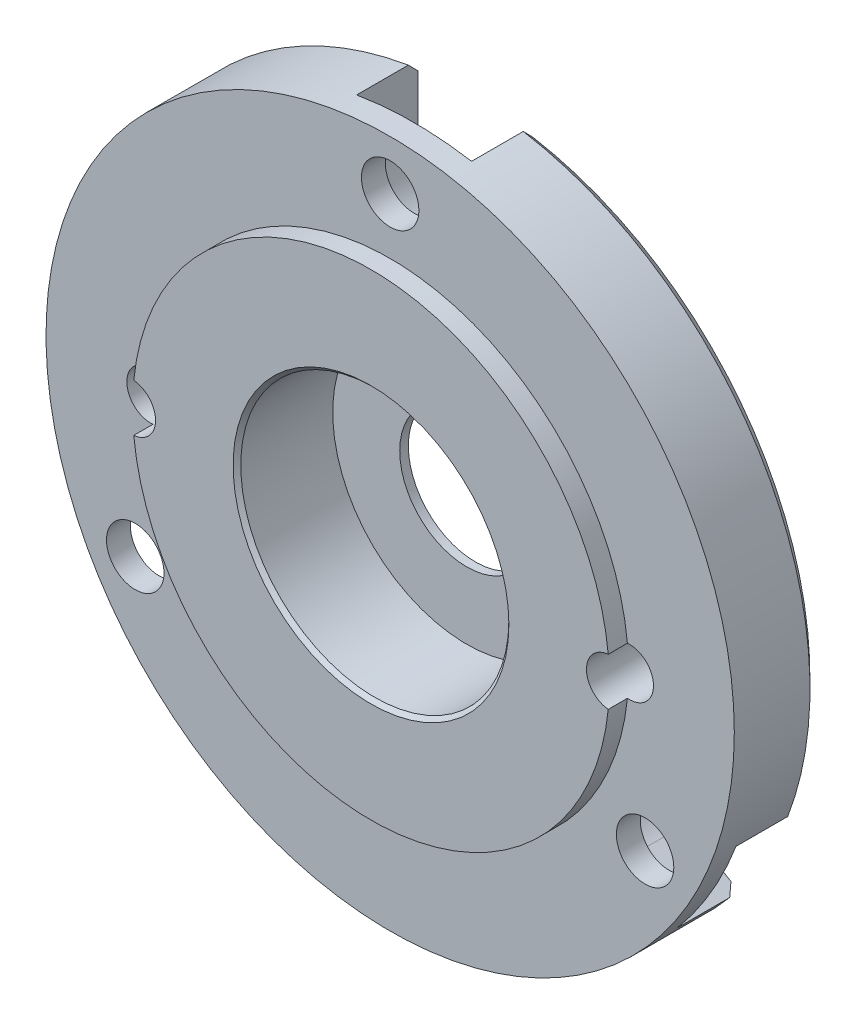
from build123d import *

# Parameters (mm, degrees)
ESQUISSE1_R             = 17.97
BOSS_EXTRU_1_DEPTH      = 4.45
ESQUISSE2_R             = 12.45
BOSS_EXTRU_2_DEPTH      = 1
CHANFREIN1_SIZE         = 0.5
ESQUISSE5_R             = 1.5
ENL_V_MAT_EXTRU_1_DEPTH = 6.45
ESQUISSE6_R             = 3.5
ENL_V_MAT_EXTRU_2_DEPTH = 6.45
ESQUISSE7_R             = 7
ENL_V_MAT_EXTRU_3_DEPTH = 5
ENL_V_MAT_EXTRU_4_DEPTH = 3.2
CHANFREIN2_SIZE         = 0.2
ESQUISSE9_R             = 1.25
ENL_V_MAT_EXTRU_5_DEPTH = 6.45


with BuildPart() as part:
    # Esquisse1 → Boss.-Extru.1 (new body)
    with BuildSketch(Plane.XY):
        with Locations((-74.842203198, 51.872077922)):
            Circle(ESQUISSE1_R)
    extrude(amount=BOSS_EXTRU_1_DEPTH)

    # Esquisse2 → Boss.-Extru.2 (add)
    with BuildSketch(Plane.XY.offset(4.45)):
        with Locations((-74.842203198, 51.872077922)):
            Circle(ESQUISSE2_R)
    extrude(amount=BOSS_EXTRU_2_DEPTH)

    # Chanfrein1
    chanfrein1_edges = [part.edges().sort_by_distance(p)[0] for p in [
        (-92.812203198, 51.872077922, 0),
    ]]
    chamfer(chanfrein1_edges, length=CHANFREIN1_SIZE)

    # Esquisse5 → Enlèv. mat.-Extru.1 (cut, through all)
    with BuildSketch(Plane(origin=(0, 0, 0), x_dir=(-1, 0, 0), z_dir=(0, 0, -1))):
        with Locations((74.842203198, 67.242077922)):
            Circle(ESQUISSE5_R)
        with Locations((61.531392742, 44.187077922)):
            Circle(ESQUISSE5_R)
        with Locations((88.153013654, 44.187077922)):
            Circle(ESQUISSE5_R)
    extrude(amount=-ENL_V_MAT_EXTRU_1_DEPTH, mode=Mode.SUBTRACT)

    # Esquisse6 → Enlèv. mat.-Extru.2 (cut, through all)
    with BuildSketch(Plane(origin=(0, 0, 0), x_dir=(-1, 0, 0), z_dir=(0, 0, -1))):
        with Locations((74.842203198, 51.872077922)):
            Circle(ESQUISSE6_R)
    extrude(amount=-ENL_V_MAT_EXTRU_2_DEPTH, mode=Mode.SUBTRACT)

    # Esquisse7 → Enlèv. mat.-Extru.3 (cut)
    with BuildSketch(Plane.XY.offset(5.45)):
        with Locations((-74.842203198, 51.872077922)):
            Circle(ESQUISSE7_R)
    extrude(amount=-ENL_V_MAT_EXTRU_3_DEPTH, mode=Mode.SUBTRACT)

    # Esquisse8 → Enlèv. mat.-Extru.4 (cut)
    with BuildSketch(Plane(origin=(0, 0, 0), x_dir=(-1, 0, 0), z_dir=(0, 0, -1))):
        with BuildLine():
            Line((71.842203198, 70.411905134), (71.842203198, 66.363654544))
            ThreePointArc((71.842203198, 66.363654544), (74.842203198, 63.363654544), (77.842203198, 66.363654544))
            Line((77.842203198, 66.363654544), (77.842203198, 70.411905134))
            Line((77.842203198, 70.411905134), (71.842203198, 70.411905134))
        make_face()
        with BuildLine():
            Line((60.379554388, 39.925212907), (63.849582418, 42.010216097))
            ThreePointArc((63.849582418, 42.010216097), (64.875970095, 46.126832224), (60.759353968, 47.153219901))
            Line((60.759353968, 47.153219901), (57.289325938, 45.068216711))
            Line((57.289325938, 45.068216711), (60.379554388, 39.925212907))
        make_face()
        with BuildLine():
            Line((92.371338943, 45.133431645), (88.865451092, 47.15755694))
            ThreePointArc((88.865451092, 47.15755694), (84.76737488, 46.059480728), (85.865451092, 41.961404517))
            Line((85.865451092, 41.961404517), (89.371338943, 39.937279222))
            Line((89.371338943, 39.937279222), (92.371338943, 45.133431645))
        make_face()
    extrude(amount=-ENL_V_MAT_EXTRU_4_DEPTH, mode=Mode.SUBTRACT)

    # Chanfrein2
    chanfrein2_edges = [part.edges().sort_by_distance(p)[0] for p in [
        (-81.842203198, 51.872077922, 5.45),
    ]]
    chamfer(chanfrein2_edges, length=CHANFREIN2_SIZE)

    # Esquisse9 → Enlèv. mat.-Extru.5 (cut, through all)
    with BuildSketch(Plane(origin=(0, 0, 0), x_dir=(-1, 0, 0), z_dir=(0, 0, -1))):
        with Locations((62.342203198, 51.872077922)):
            Circle(ESQUISSE9_R)
        with Locations((87.342203198, 51.872077922)):
            Circle(ESQUISSE9_R)
    extrude(amount=-ENL_V_MAT_EXTRU_5_DEPTH, mode=Mode.SUBTRACT)


solid = part.part
